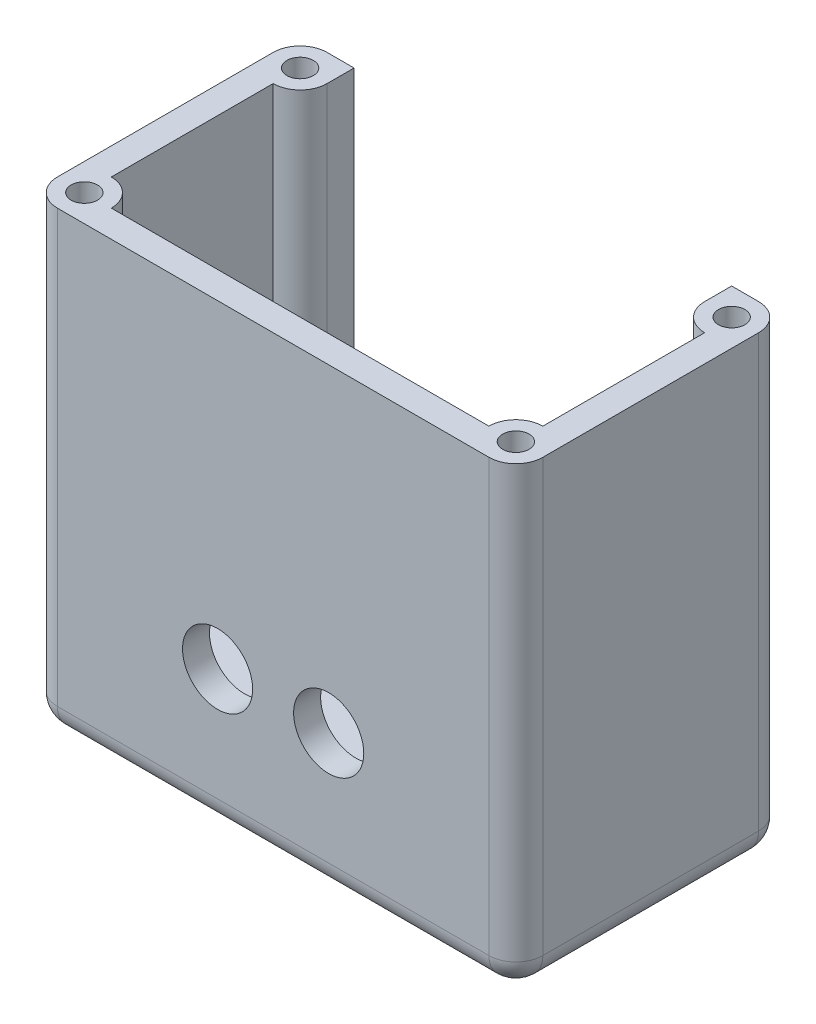
from build123d import *

# Parameters (mm, degrees)
SKETCH1_W                                           = 114.3
SKETCH1_H                                           = 114.3
BOSS_EXTRUDE1_DEPTH                                 = 53.975
CUT_EXTRUDE1_DEPTH                                  = 101.6
CBORE_FOR_0_BINDING_HEAD_MACHINE_SCREW1_D           = 1.8542
CBORE_FOR_0_BINDING_HEAD_MACHINE_SCREW1_DEPTH       = 17.73094212
CBORE_FOR_0_BINDING_HEAD_MACHINE_SCREW1_CBORE_D     = 6.223
CBORE_FOR_0_BINDING_HEAD_MACHINE_SCREW1_CBORE_DEPTH = 9.144
CBORE_FOR_0_BINDING_HEAD_MACHINE_SCREW1_TIP         = 0.55705788
SKETCH5_W                                           = 34.94
SKETCH5_H                                           = 34.94
SKETCH5_W_2                                         = 15.25
SKETCH5_H_2                                         = 15.25
CUT_EXTRUDE5_DEPTH                                  = 0.55
CUT_EXTRUDE6_REACH                                  = 135.539
SKETCH5_3_W                                         = 15.25
SKETCH5_3_H                                         = 15.25
SKETCH13_R                                          = 2.54
BOSS_EXTRUDE2_DEPTH                                 = 1.27
SKETCH13_4_R                                        = 2.54
CUT_EXTRUDE7_DEPTH                                  = 2.54
CUT_EXTRUDE8_DEPTH                                  = 0.635
CUT_EXTRUDE9_DEPTH                                  = 1.27
CBORE_FOR_M5_HEX_HEAD_BOLT2_AT_2_COUNT              = 2
CBORE_FOR_M5_HEX_HEAD_BOLT2_AT_2_PITCH              = 27.94
CBORE_FOR_M5_HEX_HEAD_BOLT2_AT_3_COUNT              = 2
CBORE_FOR_M5_HEX_HEAD_BOLT2_AT_3_PITCH              = 39.513126933
CBORE_FOR_M5_HEX_HEAD_BOLT2_AT_4_COUNT              = 2
CBORE_FOR_M5_HEX_HEAD_BOLT2_AT_4_PITCH              = 27.94
CUT_EXTRUDE10_START                                 = -2.032
CUT_EXTRUDE10_DEPTH                                 = 2.032
CIRPATTERN1_COUNT                                   = 4
SKETCH24_W                                          = 114.3
SKETCH24_H                                          = 107.95
CUT_EXTRUDE11_DEPTH                                 = 50.8
BOSS_EXTRUDE3_DEPTH                                 = 101.6
SKETCH27_R                                          = 3.81
BOSS_EXTRUDE4_DEPTH                                 = 7.62
CUT_EXTRUDE12_REACH                                 = 104.668
SKETCH26_R                                          = 8.255
CBORE_FOR_M5_HEX_HEAD_BOLT3_D                       = 2.5
CBORE_FOR_M5_HEX_HEAD_BOLT3_DEPTH                   = 8.138924226
CBORE_FOR_M5_HEX_HEAD_BOLT3_CBORE_D                 = 4.45
CBORE_FOR_M5_HEX_HEAD_BOLT3_CBORE_DEPTH             = 5.8
CBORE_FOR_M5_HEX_HEAD_BOLT3_TIP                     = 0.751075774
CBORE_FOR_0_BINDING_HEAD_MACHINE_SC_2_COUNT         = 2
CBORE_FOR_0_BINDING_HEAD_MACHINE_SC_2_PITCH         = 101.6
FILLET1_R                                           = 6.35
CUT_EXTRUDE13_REACH                                 = 99.188


with BuildPart() as part:
    # Sketch1 → Boss-Extrude1 (new, symmetric)
    with BuildSketch(Plane(origin=(0, 0, 0), x_dir=(1, 0, 0), z_dir=(0, 1, 0))):
        Rectangle(SKETCH1_W, SKETCH1_H)
    extrude(amount=BOSS_EXTRUDE1_DEPTH, both=True)

    # Sketch2 → Cut-Extrude1 (cut)
    with BuildSketch(Plane(origin=(0, 53.975, 0), x_dir=(1, 0, 0), z_dir=(0, 1, 0))):
        with BuildLine():
            Line((44.45, 50.8), (-44.45, 50.8))
            ThreePointArc((-44.45, 50.8), (-46.309871939, 46.309871939), (-50.8, 44.45))
            Line((-50.8, 44.45), (-50.8, -44.45))
            ThreePointArc((-50.8, -44.45), (-46.309871939, -46.309871939), (-44.45, -50.8))
            Line((-44.45, -50.8), (44.45, -50.8))
            ThreePointArc((44.45, -50.8), (46.309871939, -46.309871939), (50.8, -44.45))
            Line((50.8, -44.45), (50.8, 44.45))
            ThreePointArc((50.8, 44.45), (46.309871939, 46.309871939), (44.45, 50.8))
        make_face()
    extrude(amount=-CUT_EXTRUDE1_DEPTH, mode=Mode.SUBTRACT)

    # CBORE for _0 Binding Head Machine Screw1
    with Locations(Plane(origin=(-50.8, 53.975, -50.8), x_dir=(0, 0, 1), z_dir=(0, 1, 0))):
        with Locations((0, 0), (0, 101.6), (101.6, 0), (101.6, 101.6)):
            CounterBoreHole(CBORE_FOR_0_BINDING_HEAD_MACHINE_SCREW1_D / 2, CBORE_FOR_0_BINDING_HEAD_MACHINE_SCREW1_CBORE_D / 2, CBORE_FOR_0_BINDING_HEAD_MACHINE_SCREW1_CBORE_DEPTH, depth=CBORE_FOR_0_BINDING_HEAD_MACHINE_SCREW1_DEPTH)
            with Locations((0, 0, -(CBORE_FOR_0_BINDING_HEAD_MACHINE_SCREW1_DEPTH + CBORE_FOR_0_BINDING_HEAD_MACHINE_SCREW1_TIP / 2))):  # 118° drill point
                Cone(0, CBORE_FOR_0_BINDING_HEAD_MACHINE_SCREW1_D / 2, CBORE_FOR_0_BINDING_HEAD_MACHINE_SCREW1_TIP, mode=Mode.SUBTRACT)

    # Sketch5 → Cut-Extrude5 (cut)
    with BuildSketch(Plane.XY.offset(-50.8)):
        with Locations((0, 3.185)):
            Rectangle(SKETCH5_W, SKETCH5_H)
        with Locations((0, 3.185)):
            Rectangle(SKETCH5_W_2, SKETCH5_H_2, mode=Mode.SUBTRACT)
    extrude(amount=-CUT_EXTRUDE5_DEPTH, mode=Mode.SUBTRACT)

    # Sketch5_3 → Cut-Extrude6 (cut, up to next)
    with BuildSketch(Plane.XY.offset(-50.8), mode=Mode.PRIVATE) as cut_extrude6_sk1:
        with Locations((0, 3.185)):
            Rectangle(SKETCH5_3_W, SKETCH5_3_H)
    cut_extrude6_tool1 = extrude(cut_extrude6_sk1.sketch, amount=-CUT_EXTRUDE6_REACH, mode=Mode.PRIVATE) & part.part
    add(cut_extrude6_tool1.solids().sort_by_distance((0, 3.185, -50.8))[0], mode=Mode.SUBTRACT)

    # Sketch13 → Boss-Extrude2 (add)
    with BuildSketch(Plane(origin=(0, 0, -57.15), x_dir=(-1, 0, 0), z_dir=(0, 0, -1))):
        with Locations((-14.2875, 25.4)):
            Circle(SKETCH13_R)
    boss_extrude2 = extrude(amount=BOSS_EXTRUDE2_DEPTH)

    # Sketch14 → Revolve1 (revolve)
    with BuildSketch(Plane(origin=(14.2875, 25.4, -57.15), x_dir=(-1, 0, 0), z_dir=(0, -1, 0))):
        Polygon((0, 1.27), (0, 2.54), (2.286, 2.54), (2.64, 1.905), (2.64, 1.27), (2.54, 1.27), align=None)
    revolve1 = revolve(axis=Axis((14.2875, 25.4, -58.42), (0, 0, -1)))

    # Sketch13_4 → Cut-Extrude7 (cut)
    with BuildSketch(Plane(origin=(0, 0, -57.15), x_dir=(-1, 0, 0), z_dir=(0, 0, -1))):
        with Locations((14.2875, 25.4)):
            Circle(SKETCH13_4_R)
    cut_extrude7 = extrude(amount=-CUT_EXTRUDE7_DEPTH, mode=Mode.SUBTRACT)

    # Sketch13_5 → Cut-Extrude8 (cut)
    with BuildSketch(Plane(origin=(0, 0, -57.15), x_dir=(-1, 0, 0), z_dir=(0, 0, -1))):
        with BuildLine():
            Line((13.7875, 27.890301187), (13.7875, 29.177049113))
            ThreePointArc((13.7875, 29.177049113), (12.601161082, 28.816483726), (11.593423164, 28.094076836))
            Line((11.593423164, 28.094076836), (12.491448776, 27.196051224))
            ThreePointArc((12.491448776, 27.196051224), (13.088142439, 27.639004565), (13.7875, 27.890301187))
        make_face()
        with BuildLine():
            ThreePointArc((16.981576836, 28.094076836), (15.973838918, 28.816483726), (14.7875, 29.177049113))
            Line((14.7875, 29.177049113), (14.7875, 27.890301187))
            ThreePointArc((14.7875, 27.890301187), (15.486857561, 27.639004565), (16.083551224, 27.196051224))
            Line((16.083551224, 27.196051224), (16.981576836, 28.094076836))
        make_face()
        with BuildLine():
            Line((12.491448776, 23.603948776), (11.593423164, 22.705923164))
            ThreePointArc((11.593423164, 22.705923164), (12.601161082, 21.983516274), (13.7875, 21.622950887))
            Line((13.7875, 21.622950887), (13.7875, 22.909698813))
            ThreePointArc((13.7875, 22.909698813), (13.088142439, 23.160995435), (12.491448776, 23.603948776))
        make_face()
        with BuildLine():
            ThreePointArc((14.7875, 21.622950887), (15.973838918, 21.983516274), (16.981576836, 22.705923164))
            Line((16.981576836, 22.705923164), (16.083551224, 23.603948776))
            ThreePointArc((16.083551224, 23.603948776), (15.486857561, 23.160995435), (14.7875, 22.909698813))
            Line((14.7875, 22.909698813), (14.7875, 21.622950887))
        make_face()
    cut_extrude8 = extrude(amount=-CUT_EXTRUDE8_DEPTH, mode=Mode.SUBTRACT)

    # Sketch13_6 → Cut-Extrude9 (cut)
    with BuildSketch(Plane(origin=(0, 0, -57.15), x_dir=(-1, 0, 0), z_dir=(0, 0, -1))):
        with BuildLine():
            ThreePointArc((14.7875, 29.177049113), (14.2875, 29.21), (13.7875, 29.177049113))
            Line((13.7875, 29.177049113), (13.7875, 27.890301187))
            ThreePointArc((13.7875, 27.890301187), (14.2875, 27.94), (14.7875, 27.890301187))
            Line((14.7875, 27.890301187), (14.7875, 29.177049113))
        make_face()
        with BuildLine():
            Line((13.7875, 22.909698813), (13.7875, 21.622950887))
            ThreePointArc((13.7875, 21.622950887), (14.2875, 21.59), (14.7875, 21.622950887))
            Line((14.7875, 21.622950887), (14.7875, 22.909698813))
            ThreePointArc((14.7875, 22.909698813), (14.2875, 22.86), (13.7875, 22.909698813))
        make_face()
    cut_extrude9 = extrude(amount=-CUT_EXTRUDE9_DEPTH, mode=Mode.SUBTRACT)

    # Sketch17 → Cut-Revolve1 (revolve, cut)
    with BuildSketch(Plane(origin=(-14.2875, 25.4, -57.15), x_dir=(-1, 0, 0), z_dir=(0, -1, 0))):
        Polygon((0, -1.27), (0, -2.54), (2.286, -2.54), (2.64, -1.905), (2.64, -1.27), (2.54, -1.27), align=None)
    cut_revolve1 = revolve(axis=Axis((-14.2875, 25.4, -55.88), (0, 0, 1)), mode=Mode.SUBTRACT)

    # Sketch21 → CBORE for M5 Hex Head Bolt2 (revolve, cut)
    with BuildSketch(Plane(origin=(13.97, 17.155, -57.15), x_dir=(0, 1, 0), z_dir=(1, 0, 0))):
        Polygon((0, 0), (0, 18.288), (2.75, 16.635633298), (2.75, 5.8), (2.25, 5.8), (2.25, 0), align=None)
    cbore_for_m5_hex_head_bolt2 = revolve(axis=Axis((13.97, 17.155, -63.5), (0, 0, 1)), mode=Mode.SUBTRACT)

    # CBORE for M5 Hex Head Bolt2 at 2: CBORE for M5 Hex Head Bolt2 ×2
    with Locations(*[(-i * CBORE_FOR_M5_HEX_HEAD_BOLT2_AT_2_PITCH, 0, 0) for i in range(1, CBORE_FOR_M5_HEX_HEAD_BOLT2_AT_2_COUNT)]):
        add(cbore_for_m5_hex_head_bolt2, mode=Mode.SUBTRACT)

    # CBORE for M5 Hex Head Bolt2 at 3: CBORE for M5 Hex Head Bolt2 ×2
    with Locations(*[Vector(-0.7071067811865476, -0.7071067811865476, 0) * (i * CBORE_FOR_M5_HEX_HEAD_BOLT2_AT_3_PITCH) for i in range(1, CBORE_FOR_M5_HEX_HEAD_BOLT2_AT_3_COUNT)]):
        add(cbore_for_m5_hex_head_bolt2, mode=Mode.SUBTRACT)

    # CBORE for M5 Hex Head Bolt2 at 4: CBORE for M5 Hex Head Bolt2 ×2
    with Locations(*[(0, -i * CBORE_FOR_M5_HEX_HEAD_BOLT2_AT_4_PITCH, 0) for i in range(1, CBORE_FOR_M5_HEX_HEAD_BOLT2_AT_4_COUNT)]):
        add(cbore_for_m5_hex_head_bolt2, mode=Mode.SUBTRACT)

    # Sketch23 → Cut-Extrude10 (cut)
    with BuildSketch(Plane(origin=(0, 0, -59.69), x_dir=(-1, 0, 0), z_dir=(0, 0, -1)).offset(CUT_EXTRUDE10_START)):
        with BuildLine():
            Line((-14.7875, 27.992219127), (-14.7875, 22.807780873))
            ThreePointArc((-14.7875, 22.807780873), (-14.2875, 22.76), (-13.7875, 22.807780873))
            Line((-13.7875, 22.807780873), (-13.7875, 27.992219127))
            ThreePointArc((-13.7875, 27.992219127), (-14.2875, 28.04), (-14.7875, 27.992219127))
        make_face()
    cut_extrude10 = extrude(amount=CUT_EXTRUDE10_DEPTH, mode=Mode.SUBTRACT)

    # CirPattern1: Boss-Extrude2, Revolve1, Cut-Extrude7, Cut-Extrude8, Cut-Extrude9, Cut-Revolve1, Cut-Extrude10 ×4 about axis
    cirpattern1_axis = Axis((0, 3.185, 62.992), (0, 0, -1))
    add([boss_extrude2.rotate(cirpattern1_axis, i * 360 / CIRPATTERN1_COUNT) for i in range(1, CIRPATTERN1_COUNT)])
    add([revolve1.rotate(cirpattern1_axis, i * 360 / CIRPATTERN1_COUNT) for i in range(1, CIRPATTERN1_COUNT)])
    add([cut_extrude7.rotate(cirpattern1_axis, i * 360 / CIRPATTERN1_COUNT) for i in range(1, CIRPATTERN1_COUNT)], mode=Mode.SUBTRACT)
    add([cut_extrude8.rotate(cirpattern1_axis, i * 360 / CIRPATTERN1_COUNT) for i in range(1, CIRPATTERN1_COUNT)], mode=Mode.SUBTRACT)
    add([cut_extrude9.rotate(cirpattern1_axis, i * 360 / CIRPATTERN1_COUNT) for i in range(1, CIRPATTERN1_COUNT)], mode=Mode.SUBTRACT)
    add([cut_revolve1.rotate(cirpattern1_axis, i * 360 / CIRPATTERN1_COUNT) for i in range(1, CIRPATTERN1_COUNT)], mode=Mode.SUBTRACT)
    add([cut_extrude10.rotate(cirpattern1_axis, i * 360 / CIRPATTERN1_COUNT) for i in range(1, CIRPATTERN1_COUNT)], mode=Mode.SUBTRACT)

    # Sketch24 → Cut-Extrude11 (cut)
    with BuildSketch(Plane.XY.offset(57.15)):
        Rectangle(SKETCH24_W, SKETCH24_H)
    extrude(amount=-CUT_EXTRUDE11_DEPTH, mode=Mode.SUBTRACT)

    # Sketch25 → Boss-Extrude3 (add)
    with BuildSketch(Plane(origin=(0, -47.625, 0), x_dir=(1, 0, 0), z_dir=(0, 1, 0))):
        with BuildLine():
            Line((-50.8, -6.35), (50.8, -6.35))
            Line((50.8, -6.35), (50.8, 6.35))
            ThreePointArc((50.8, 6.35), (46.309871939, 4.490128061), (44.45, 0))
            Line((44.45, 0), (-44.45, 0))
            ThreePointArc((-44.45, 0), (-46.309871939, 4.490128061), (-50.8, 6.35))
            Line((-50.8, 6.35), (-50.8, -6.35))
        make_face()
    extrude(amount=BOSS_EXTRUDE3_DEPTH)

    # Sketch27 → Boss-Extrude4 (add)
    with BuildSketch(Plane(origin=(0, -47.625, 0), x_dir=(1, 0, 0), z_dir=(0, 1, 0))):
        with Locations((-10.75, 9.652)):
            Circle(SKETCH27_R)
        with Locations((10.75, 9.652)):
            Circle(SKETCH27_R)
        with Locations((10.75, 35.652)):
            Circle(SKETCH27_R)
        with Locations((-10.75, 35.652)):
            Circle(SKETCH27_R)
    extrude(amount=BOSS_EXTRUDE4_DEPTH)

    # Sketch26 → Cut-Extrude12 (cut, up to next)
    with BuildSketch(Plane.XY.offset(6.35), mode=Mode.PRIVATE) as cut_extrude12_sk1:
        with Locations((-13.081, -21.1201)):
            Circle(SKETCH26_R)
    cut_extrude12_tool1 = extrude(cut_extrude12_sk1.sketch, amount=-CUT_EXTRUDE12_REACH, mode=Mode.PRIVATE) & part.part
    # Sketch26 → Cut-Extrude12 (cut, up to next)
    with BuildSketch(Plane.XY.offset(6.35), mode=Mode.PRIVATE) as cut_extrude12_sk2:
        with Locations((13.081, -21.1201)):
            Circle(SKETCH26_R)
    cut_extrude12_tool2 = extrude(cut_extrude12_sk2.sketch, amount=-CUT_EXTRUDE12_REACH, mode=Mode.PRIVATE) & part.part
    add(cut_extrude12_tool1.solids().sort_by_distance((-13.081, -21.1201, 6.35))[0], mode=Mode.SUBTRACT)
    add(cut_extrude12_tool2.solids().sort_by_distance((13.081, -21.1201, 6.35))[0], mode=Mode.SUBTRACT)

    # CBORE for M5 Hex Head Bolt3
    with Locations(Plane(origin=(-10.75, -40.005, -35.652), x_dir=(0, 0, 1), z_dir=(0, 1, 0))):
        with Locations((0, 0), (0, 21.5), (26, 21.5), (26, 0)):
            CounterBoreHole(CBORE_FOR_M5_HEX_HEAD_BOLT3_D / 2, CBORE_FOR_M5_HEX_HEAD_BOLT3_CBORE_D / 2, CBORE_FOR_M5_HEX_HEAD_BOLT3_CBORE_DEPTH, depth=CBORE_FOR_M5_HEX_HEAD_BOLT3_DEPTH)
            with Locations((0, 0, -(CBORE_FOR_M5_HEX_HEAD_BOLT3_DEPTH + CBORE_FOR_M5_HEX_HEAD_BOLT3_TIP / 2))):  # 118° drill point
                Cone(0, CBORE_FOR_M5_HEX_HEAD_BOLT3_D / 2, CBORE_FOR_M5_HEX_HEAD_BOLT3_TIP, mode=Mode.SUBTRACT)

    # Sketch29 → CBORE for _0 Binding Head Machine Screw2 (revolve, cut)
    with BuildSketch(Plane(origin=(50.8, 53.975, 0), x_dir=(0, 0, 1), z_dir=(1, 0, 0))):
        Polygon((0, 0), (0, 8.89), (0.9271, 8.33294212), (0.9271, 9.144), (3.1115, 9.144), (3.1115, 0), align=None)
    cbore_for_0_binding_head_machine_screw2 = revolve(axis=Axis((50.8, 60.325, 0), (0, -1, 0)), mode=Mode.SUBTRACT)

    # CBORE for _0 Binding Head Machine Sc 2: CBORE for _0 Binding Head Machine Screw2 ×2
    with Locations(*[(-i * CBORE_FOR_0_BINDING_HEAD_MACHINE_SC_2_PITCH, 0, 0) for i in range(1, CBORE_FOR_0_BINDING_HEAD_MACHINE_SC_2_COUNT)]):
        add(cbore_for_0_binding_head_machine_screw2, mode=Mode.SUBTRACT)

    # Fillet1
    fillet1_edges = [part.edges().sort_by_distance(p)[0] for p in [
        (57.15, -53.975, -25.4),
        (0, -53.975, -57.15),
        (-57.15, -53.975, -25.4),
        (0, -53.975, 6.35),
        (57.15, 0, 6.35),
        (57.15, 0, -57.15),
        (-57.15, 0, 6.35),
        (-57.15, 0, -57.15),
    ]]
    fillet(fillet1_edges, radius=FILLET1_R)

    # Sketch30 → Cut-Extrude13 (cut, up to next)
    with BuildSketch(Plane.XY.offset(-50.8), mode=Mode.PRIVATE) as cut_extrude13_sk1:
        Polygon((44.45, 53.975), (-44.45, 53.975), (-44.45, -47.625), (-6.35, -47.625), (-6.35, -53.975), (6.35, -53.975), (6.35, -47.625), (44.45, -47.625), align=None)
    cut_extrude13_tool1 = extrude(cut_extrude13_sk1.sketch, amount=-CUT_EXTRUDE13_REACH, mode=Mode.PRIVATE) & part.part
    add(cut_extrude13_tool1.solids().sort_by_distance((0, 2.697345, -50.8))[0], mode=Mode.SUBTRACT)


solid = part.part
